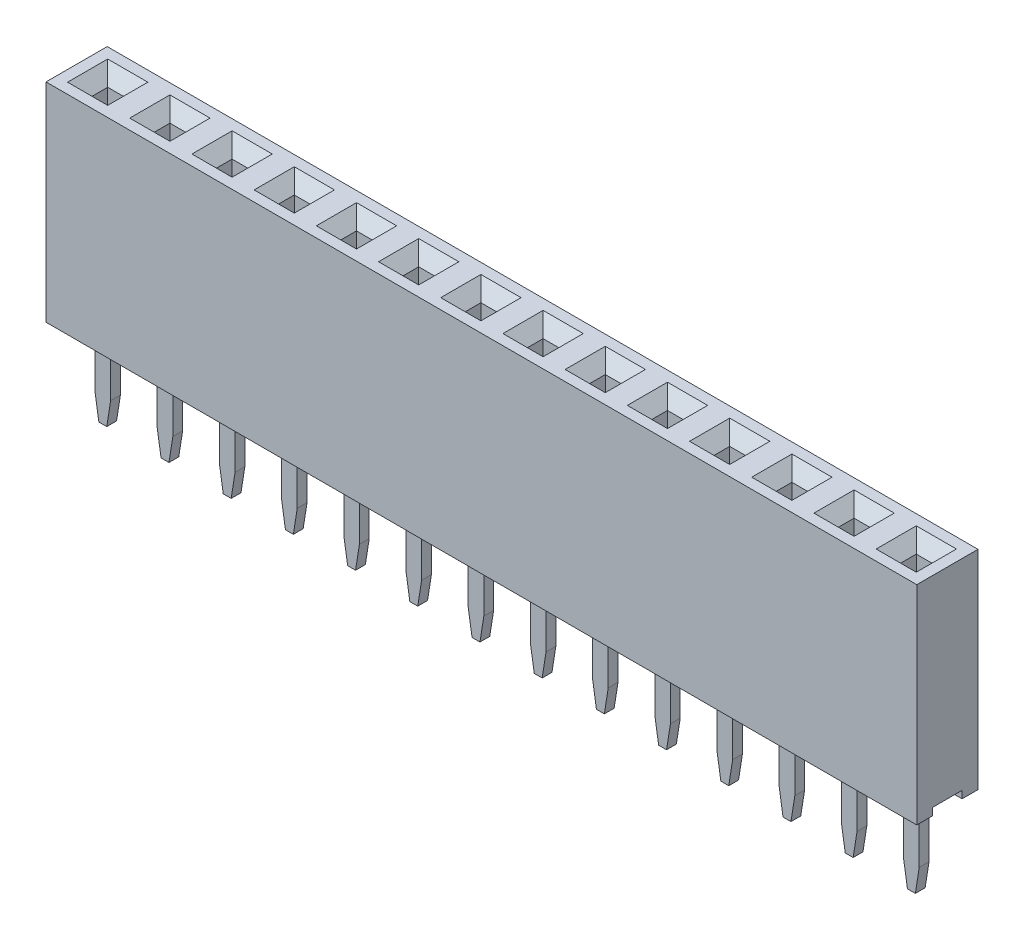
from build123d import *
from OCP.BRepFilletAPI import BRepFilletAPI_MakeChamfer

# Parameters (mm, degrees)
SKETCH1_W                   = 2.54
SKETCH1_H                   = 2.5
BOSS_EXTRUDE1_DEPTH         = 8.5
SKETCH2_W                   = 2.54
SKETCH2_H                   = 1.2
CUT_EXTRUDE1_DEPTH          = 0.3
CUT_EXTRUDE2_START          = -6
SKETCH3_W                   = 0.64
SKETCH3_H                   = 0.64
CUT_EXTRUDE2_DEPTH          = 15.68477979
CHAMFER1_SIZE               = 0.5
SKETCH4_W                   = 0.64
SKETCH4_H                   = 0.4
BOSS_EXTRUDE2_DEPTH         = 3.8
CHAMFER2_SIZE               = 1
CHAMFER2_SIZE2              = 0.15838444
LPATTERN1_COUNT             = 14
LPATTERN1_PITCH             = 2.54
CHAMFER1_OF_LPATTERN1_SIZE  = 0.5
CHAMFER2_OF_LPATTERN1_SIZE  = 1
CHAMFER2_OF_LPATTERN1_SIZE2 = 0.15838444


with BuildPart() as part:
    # Sketch1 → Boss-Extrude1 (new body)
    with BuildSketch(Plane(origin=(0, 0, 0), x_dir=(1, 0, 0), z_dir=(0, 1, 0))):
        Rectangle(SKETCH1_W, SKETCH1_H)
    boss_extrude1 = extrude(amount=BOSS_EXTRUDE1_DEPTH)

    # Sketch2 → Cut-Extrude1 (cut)
    with BuildSketch(Plane.XZ):
        Rectangle(SKETCH2_W, SKETCH2_H)
    cut_extrude1 = extrude(amount=-CUT_EXTRUDE1_DEPTH, mode=Mode.SUBTRACT)

    # Sketch3 → Cut-Extrude2 (cut)
    with BuildSketch(Plane(origin=(0, 8.5, 0), x_dir=(1, 0, 0), z_dir=(0, 1, 0)).offset(CUT_EXTRUDE2_START)):
        Rectangle(SKETCH3_W, SKETCH3_H)
    cut_extrude2 = extrude(amount=CUT_EXTRUDE2_DEPTH, mode=Mode.SUBTRACT)

    # Chamfer1
    chamfer1_edges = [part.edges().sort_by_distance(p)[0] for p in [
        (0, 8.5, 0.32),
        (-0.32, 8.5, 0),
        (0, 8.5, -0.32),
        (0.32, 8.5, 0),
    ]]
    chamfer(chamfer1_edges, length=CHAMFER1_SIZE)

    # Sketch4 → Boss-Extrude2 (add)
    with BuildSketch(Plane.XZ.offset(-0.3)):
        Rectangle(SKETCH4_W, SKETCH4_H)
    boss_extrude2 = extrude(amount=BOSS_EXTRUDE2_DEPTH)

    # Chamfer2: one chamfer whose edges measure the first distance from different faces: ONE call of the kernel's chamfer builder (chamfer() names one face for all edges)
    chamfer2_edges_1 = [part.edges().sort_by_distance(p)[0] for p in [
        (0.32, -3.5, 0),
    ]]
    chamfer2_side_1 = [part.faces().sort_by_distance(p)[0] for p in [
        (0.32, -1.6, 0),
    ]]
    chamfer2_edges_2 = [part.edges().sort_by_distance(p)[0] for p in [
        (-0.32, -3.5, 0),
    ]]
    chamfer2_side_2 = [part.faces().sort_by_distance(p)[0] for p in [
        (-0.32, -1.6, 0),
    ]]
    chamfer2 = BRepFilletAPI_MakeChamfer(part.part.solid().wrapped)
    for e in chamfer2_edges_1:
        chamfer2.Add(CHAMFER2_SIZE, CHAMFER2_SIZE2, e.wrapped, chamfer2_side_1[0].wrapped)  # the first distance lies on this face
    for e in chamfer2_edges_2:
        chamfer2.Add(CHAMFER2_SIZE, CHAMFER2_SIZE2, e.wrapped, chamfer2_side_2[0].wrapped)  # the first distance lies on this face
    add(Compound.cast(chamfer2.Shape()), mode=Mode.REPLACE)

    # LPattern1: Boss-Extrude1, Cut-Extrude1, Cut-Extrude2, Boss-Extrude2 ×14
    with Locations(*[(-i * LPATTERN1_PITCH, 0, 0) for i in range(1, LPATTERN1_COUNT)]):
        add(boss_extrude1)
        add(cut_extrude1, mode=Mode.SUBTRACT)
        add(cut_extrude2, mode=Mode.SUBTRACT)
        add(boss_extrude2)

    # Chamfer1 of LPattern1
    chamfer1_of_lpattern1_edges = [part.edges().sort_by_distance(p)[0] for p in [
        (-2.54, 8.5, 0.32),
        (-2.86, 8.5, 0),
        (-2.54, 8.5, -0.32),
        (-2.22, 8.5, 0),
        (-5.08, 8.5, 0.32),
        (-5.4, 8.5, 0),
        (-5.08, 8.5, -0.32),
        (-4.76, 8.5, 0),
        (-7.62, 8.5, 0.32),
        (-7.94, 8.5, 0),
        (-7.62, 8.5, -0.32),
        (-7.3, 8.5, 0),
        (-10.16, 8.5, 0.32),
        (-10.48, 8.5, 0),
        (-10.16, 8.5, -0.32),
        (-9.84, 8.5, 0),
        (-12.7, 8.5, 0.32),
        (-13.02, 8.5, 0),
        (-12.7, 8.5, -0.32),
        (-12.38, 8.5, 0),
        (-15.24, 8.5, 0.32),
        (-15.56, 8.5, 0),
        (-15.24, 8.5, -0.32),
        (-14.92, 8.5, 0),
        (-17.78, 8.5, 0.32),
        (-18.1, 8.5, 0),
        (-17.78, 8.5, -0.32),
        (-17.46, 8.5, 0),
        (-20.32, 8.5, 0.32),
        (-20.64, 8.5, 0),
        (-20.32, 8.5, -0.32),
        (-20, 8.5, 0),
        (-22.86, 8.5, 0.32),
        (-23.18, 8.5, 0),
        (-22.86, 8.5, -0.32),
        (-22.54, 8.5, 0),
        (-25.4, 8.5, 0.32),
        (-25.72, 8.5, 0),
        (-25.4, 8.5, -0.32),
        (-25.08, 8.5, 0),
        (-27.94, 8.5, 0.32),
        (-28.26, 8.5, 0),
        (-27.94, 8.5, -0.32),
        (-27.62, 8.5, 0),
        (-30.48, 8.5, 0.32),
        (-30.8, 8.5, 0),
        (-30.48, 8.5, -0.32),
        (-30.16, 8.5, 0),
        (-33.02, 8.5, 0.32),
        (-33.34, 8.5, 0),
        (-33.02, 8.5, -0.32),
        (-32.7, 8.5, 0),
    ]]
    chamfer(chamfer1_of_lpattern1_edges, length=CHAMFER1_OF_LPATTERN1_SIZE)

    # Chamfer2 of LPattern1: one chamfer whose edges measure the first distance from different faces: ONE call of the kernel's chamfer builder (chamfer() names one face for all edges)
    chamfer2_of_lpattern1_edges_1 = [part.edges().sort_by_distance(p)[0] for p in [
        (-2.22, -3.5, 0),
    ]]
    chamfer2_of_lpattern1_side_1 = [part.faces().sort_by_distance(p)[0] for p in [
        (-2.22, -1.6, 0),
    ]]
    chamfer2_of_lpattern1_edges_2 = [part.edges().sort_by_distance(p)[0] for p in [
        (-2.86, -3.5, 0),
    ]]
    chamfer2_of_lpattern1_side_2 = [part.faces().sort_by_distance(p)[0] for p in [
        (-2.86, -1.6, 0),
    ]]
    chamfer2_of_lpattern1_edges_3 = [part.edges().sort_by_distance(p)[0] for p in [
        (-4.76, -3.5, 0),
    ]]
    chamfer2_of_lpattern1_side_3 = [part.faces().sort_by_distance(p)[0] for p in [
        (-4.76, -1.6, 0),
    ]]
    chamfer2_of_lpattern1_edges_4 = [part.edges().sort_by_distance(p)[0] for p in [
        (-5.4, -3.5, 0),
    ]]
    chamfer2_of_lpattern1_side_4 = [part.faces().sort_by_distance(p)[0] for p in [
        (-5.4, -1.6, 0),
    ]]
    chamfer2_of_lpattern1_edges_5 = [part.edges().sort_by_distance(p)[0] for p in [
        (-7.3, -3.5, 0),
    ]]
    chamfer2_of_lpattern1_side_5 = [part.faces().sort_by_distance(p)[0] for p in [
        (-7.3, -1.6, 0),
    ]]
    chamfer2_of_lpattern1_edges_6 = [part.edges().sort_by_distance(p)[0] for p in [
        (-7.94, -3.5, 0),
    ]]
    chamfer2_of_lpattern1_side_6 = [part.faces().sort_by_distance(p)[0] for p in [
        (-7.94, -1.6, 0),
    ]]
    chamfer2_of_lpattern1_edges_7 = [part.edges().sort_by_distance(p)[0] for p in [
        (-9.84, -3.5, 0),
    ]]
    chamfer2_of_lpattern1_side_7 = [part.faces().sort_by_distance(p)[0] for p in [
        (-9.84, -1.6, 0),
    ]]
    chamfer2_of_lpattern1_edges_8 = [part.edges().sort_by_distance(p)[0] for p in [
        (-10.48, -3.5, 0),
    ]]
    chamfer2_of_lpattern1_side_8 = [part.faces().sort_by_distance(p)[0] for p in [
        (-10.48, -1.6, 0),
    ]]
    chamfer2_of_lpattern1_edges_9 = [part.edges().sort_by_distance(p)[0] for p in [
        (-12.38, -3.5, 0),
    ]]
    chamfer2_of_lpattern1_side_9 = [part.faces().sort_by_distance(p)[0] for p in [
        (-12.38, -1.6, 0),
    ]]
    chamfer2_of_lpattern1_edges_10 = [part.edges().sort_by_distance(p)[0] for p in [
        (-13.02, -3.5, 0),
    ]]
    chamfer2_of_lpattern1_side_10 = [part.faces().sort_by_distance(p)[0] for p in [
        (-13.02, -1.6, 0),
    ]]
    chamfer2_of_lpattern1_edges_11 = [part.edges().sort_by_distance(p)[0] for p in [
        (-14.92, -3.5, 0),
    ]]
    chamfer2_of_lpattern1_side_11 = [part.faces().sort_by_distance(p)[0] for p in [
        (-14.92, -1.6, 0),
    ]]
    chamfer2_of_lpattern1_edges_12 = [part.edges().sort_by_distance(p)[0] for p in [
        (-15.56, -3.5, 0),
    ]]
    chamfer2_of_lpattern1_side_12 = [part.faces().sort_by_distance(p)[0] for p in [
        (-15.56, -1.6, 0),
    ]]
    chamfer2_of_lpattern1_edges_13 = [part.edges().sort_by_distance(p)[0] for p in [
        (-17.46, -3.5, 0),
    ]]
    chamfer2_of_lpattern1_side_13 = [part.faces().sort_by_distance(p)[0] for p in [
        (-17.46, -1.6, 0),
    ]]
    chamfer2_of_lpattern1_edges_14 = [part.edges().sort_by_distance(p)[0] for p in [
        (-18.1, -3.5, 0),
    ]]
    chamfer2_of_lpattern1_side_14 = [part.faces().sort_by_distance(p)[0] for p in [
        (-18.1, -1.6, 0),
    ]]
    chamfer2_of_lpattern1_edges_15 = [part.edges().sort_by_distance(p)[0] for p in [
        (-20, -3.5, 0),
    ]]
    chamfer2_of_lpattern1_side_15 = [part.faces().sort_by_distance(p)[0] for p in [
        (-20, -1.6, 0),
    ]]
    chamfer2_of_lpattern1_edges_16 = [part.edges().sort_by_distance(p)[0] for p in [
        (-20.64, -3.5, 0),
    ]]
    chamfer2_of_lpattern1_side_16 = [part.faces().sort_by_distance(p)[0] for p in [
        (-20.64, -1.6, 0),
    ]]
    chamfer2_of_lpattern1_edges_17 = [part.edges().sort_by_distance(p)[0] for p in [
        (-22.54, -3.5, 0),
    ]]
    chamfer2_of_lpattern1_side_17 = [part.faces().sort_by_distance(p)[0] for p in [
        (-22.54, -1.6, 0),
    ]]
    chamfer2_of_lpattern1_edges_18 = [part.edges().sort_by_distance(p)[0] for p in [
        (-23.18, -3.5, 0),
    ]]
    chamfer2_of_lpattern1_side_18 = [part.faces().sort_by_distance(p)[0] for p in [
        (-23.18, -1.6, 0),
    ]]
    chamfer2_of_lpattern1_edges_19 = [part.edges().sort_by_distance(p)[0] for p in [
        (-25.08, -3.5, 0),
    ]]
    chamfer2_of_lpattern1_side_19 = [part.faces().sort_by_distance(p)[0] for p in [
        (-25.08, -1.6, 0),
    ]]
    chamfer2_of_lpattern1_edges_20 = [part.edges().sort_by_distance(p)[0] for p in [
        (-25.72, -3.5, 0),
    ]]
    chamfer2_of_lpattern1_side_20 = [part.faces().sort_by_distance(p)[0] for p in [
        (-25.72, -1.6, 0),
    ]]
    chamfer2_of_lpattern1_edges_21 = [part.edges().sort_by_distance(p)[0] for p in [
        (-27.62, -3.5, 0),
    ]]
    chamfer2_of_lpattern1_side_21 = [part.faces().sort_by_distance(p)[0] for p in [
        (-27.62, -1.6, 0),
    ]]
    chamfer2_of_lpattern1_edges_22 = [part.edges().sort_by_distance(p)[0] for p in [
        (-28.26, -3.5, 0),
    ]]
    chamfer2_of_lpattern1_side_22 = [part.faces().sort_by_distance(p)[0] for p in [
        (-28.26, -1.6, 0),
    ]]
    chamfer2_of_lpattern1_edges_23 = [part.edges().sort_by_distance(p)[0] for p in [
        (-30.16, -3.5, 0),
    ]]
    chamfer2_of_lpattern1_side_23 = [part.faces().sort_by_distance(p)[0] for p in [
        (-30.16, -1.6, 0),
    ]]
    chamfer2_of_lpattern1_edges_24 = [part.edges().sort_by_distance(p)[0] for p in [
        (-30.8, -3.5, 0),
    ]]
    chamfer2_of_lpattern1_side_24 = [part.faces().sort_by_distance(p)[0] for p in [
        (-30.8, -1.6, 0),
    ]]
    chamfer2_of_lpattern1_edges_25 = [part.edges().sort_by_distance(p)[0] for p in [
        (-32.7, -3.5, 0),
    ]]
    chamfer2_of_lpattern1_side_25 = [part.faces().sort_by_distance(p)[0] for p in [
        (-32.7, -1.6, 0),
    ]]
    chamfer2_of_lpattern1_edges_26 = [part.edges().sort_by_distance(p)[0] for p in [
        (-33.34, -3.5, 0),
    ]]
    chamfer2_of_lpattern1_side_26 = [part.faces().sort_by_distance(p)[0] for p in [
        (-33.34, -1.6, 0),
    ]]
    chamfer2_of_lpattern1 = BRepFilletAPI_MakeChamfer(part.part.solid().wrapped)
    for e in chamfer2_of_lpattern1_edges_1:
        chamfer2_of_lpattern1.Add(CHAMFER2_OF_LPATTERN1_SIZE, CHAMFER2_OF_LPATTERN1_SIZE2, e.wrapped, chamfer2_of_lpattern1_side_1[0].wrapped)  # the first distance lies on this face
    for e in chamfer2_of_lpattern1_edges_2:
        chamfer2_of_lpattern1.Add(CHAMFER2_OF_LPATTERN1_SIZE, CHAMFER2_OF_LPATTERN1_SIZE2, e.wrapped, chamfer2_of_lpattern1_side_2[0].wrapped)  # the first distance lies on this face
    for e in chamfer2_of_lpattern1_edges_3:
        chamfer2_of_lpattern1.Add(CHAMFER2_OF_LPATTERN1_SIZE, CHAMFER2_OF_LPATTERN1_SIZE2, e.wrapped, chamfer2_of_lpattern1_side_3[0].wrapped)  # the first distance lies on this face
    for e in chamfer2_of_lpattern1_edges_4:
        chamfer2_of_lpattern1.Add(CHAMFER2_OF_LPATTERN1_SIZE, CHAMFER2_OF_LPATTERN1_SIZE2, e.wrapped, chamfer2_of_lpattern1_side_4[0].wrapped)  # the first distance lies on this face
    for e in chamfer2_of_lpattern1_edges_5:
        chamfer2_of_lpattern1.Add(CHAMFER2_OF_LPATTERN1_SIZE, CHAMFER2_OF_LPATTERN1_SIZE2, e.wrapped, chamfer2_of_lpattern1_side_5[0].wrapped)  # the first distance lies on this face
    for e in chamfer2_of_lpattern1_edges_6:
        chamfer2_of_lpattern1.Add(CHAMFER2_OF_LPATTERN1_SIZE, CHAMFER2_OF_LPATTERN1_SIZE2, e.wrapped, chamfer2_of_lpattern1_side_6[0].wrapped)  # the first distance lies on this face
    for e in chamfer2_of_lpattern1_edges_7:
        chamfer2_of_lpattern1.Add(CHAMFER2_OF_LPATTERN1_SIZE, CHAMFER2_OF_LPATTERN1_SIZE2, e.wrapped, chamfer2_of_lpattern1_side_7[0].wrapped)  # the first distance lies on this face
    for e in chamfer2_of_lpattern1_edges_8:
        chamfer2_of_lpattern1.Add(CHAMFER2_OF_LPATTERN1_SIZE, CHAMFER2_OF_LPATTERN1_SIZE2, e.wrapped, chamfer2_of_lpattern1_side_8[0].wrapped)  # the first distance lies on this face
    for e in chamfer2_of_lpattern1_edges_9:
        chamfer2_of_lpattern1.Add(CHAMFER2_OF_LPATTERN1_SIZE, CHAMFER2_OF_LPATTERN1_SIZE2, e.wrapped, chamfer2_of_lpattern1_side_9[0].wrapped)  # the first distance lies on this face
    for e in chamfer2_of_lpattern1_edges_10:
        chamfer2_of_lpattern1.Add(CHAMFER2_OF_LPATTERN1_SIZE, CHAMFER2_OF_LPATTERN1_SIZE2, e.wrapped, chamfer2_of_lpattern1_side_10[0].wrapped)  # the first distance lies on this face
    for e in chamfer2_of_lpattern1_edges_11:
        chamfer2_of_lpattern1.Add(CHAMFER2_OF_LPATTERN1_SIZE, CHAMFER2_OF_LPATTERN1_SIZE2, e.wrapped, chamfer2_of_lpattern1_side_11[0].wrapped)  # the first distance lies on this face
    for e in chamfer2_of_lpattern1_edges_12:
        chamfer2_of_lpattern1.Add(CHAMFER2_OF_LPATTERN1_SIZE, CHAMFER2_OF_LPATTERN1_SIZE2, e.wrapped, chamfer2_of_lpattern1_side_12[0].wrapped)  # the first distance lies on this face
    for e in chamfer2_of_lpattern1_edges_13:
        chamfer2_of_lpattern1.Add(CHAMFER2_OF_LPATTERN1_SIZE, CHAMFER2_OF_LPATTERN1_SIZE2, e.wrapped, chamfer2_of_lpattern1_side_13[0].wrapped)  # the first distance lies on this face
    for e in chamfer2_of_lpattern1_edges_14:
        chamfer2_of_lpattern1.Add(CHAMFER2_OF_LPATTERN1_SIZE, CHAMFER2_OF_LPATTERN1_SIZE2, e.wrapped, chamfer2_of_lpattern1_side_14[0].wrapped)  # the first distance lies on this face
    for e in chamfer2_of_lpattern1_edges_15:
        chamfer2_of_lpattern1.Add(CHAMFER2_OF_LPATTERN1_SIZE, CHAMFER2_OF_LPATTERN1_SIZE2, e.wrapped, chamfer2_of_lpattern1_side_15[0].wrapped)  # the first distance lies on this face
    for e in chamfer2_of_lpattern1_edges_16:
        chamfer2_of_lpattern1.Add(CHAMFER2_OF_LPATTERN1_SIZE, CHAMFER2_OF_LPATTERN1_SIZE2, e.wrapped, chamfer2_of_lpattern1_side_16[0].wrapped)  # the first distance lies on this face
    for e in chamfer2_of_lpattern1_edges_17:
        chamfer2_of_lpattern1.Add(CHAMFER2_OF_LPATTERN1_SIZE, CHAMFER2_OF_LPATTERN1_SIZE2, e.wrapped, chamfer2_of_lpattern1_side_17[0].wrapped)  # the first distance lies on this face
    for e in chamfer2_of_lpattern1_edges_18:
        chamfer2_of_lpattern1.Add(CHAMFER2_OF_LPATTERN1_SIZE, CHAMFER2_OF_LPATTERN1_SIZE2, e.wrapped, chamfer2_of_lpattern1_side_18[0].wrapped)  # the first distance lies on this face
    for e in chamfer2_of_lpattern1_edges_19:
        chamfer2_of_lpattern1.Add(CHAMFER2_OF_LPATTERN1_SIZE, CHAMFER2_OF_LPATTERN1_SIZE2, e.wrapped, chamfer2_of_lpattern1_side_19[0].wrapped)  # the first distance lies on this face
    for e in chamfer2_of_lpattern1_edges_20:
        chamfer2_of_lpattern1.Add(CHAMFER2_OF_LPATTERN1_SIZE, CHAMFER2_OF_LPATTERN1_SIZE2, e.wrapped, chamfer2_of_lpattern1_side_20[0].wrapped)  # the first distance lies on this face
    for e in chamfer2_of_lpattern1_edges_21:
        chamfer2_of_lpattern1.Add(CHAMFER2_OF_LPATTERN1_SIZE, CHAMFER2_OF_LPATTERN1_SIZE2, e.wrapped, chamfer2_of_lpattern1_side_21[0].wrapped)  # the first distance lies on this face
    for e in chamfer2_of_lpattern1_edges_22:
        chamfer2_of_lpattern1.Add(CHAMFER2_OF_LPATTERN1_SIZE, CHAMFER2_OF_LPATTERN1_SIZE2, e.wrapped, chamfer2_of_lpattern1_side_22[0].wrapped)  # the first distance lies on this face
    for e in chamfer2_of_lpattern1_edges_23:
        chamfer2_of_lpattern1.Add(CHAMFER2_OF_LPATTERN1_SIZE, CHAMFER2_OF_LPATTERN1_SIZE2, e.wrapped, chamfer2_of_lpattern1_side_23[0].wrapped)  # the first distance lies on this face
    for e in chamfer2_of_lpattern1_edges_24:
        chamfer2_of_lpattern1.Add(CHAMFER2_OF_LPATTERN1_SIZE, CHAMFER2_OF_LPATTERN1_SIZE2, e.wrapped, chamfer2_of_lpattern1_side_24[0].wrapped)  # the first distance lies on this face
    for e in chamfer2_of_lpattern1_edges_25:
        chamfer2_of_lpattern1.Add(CHAMFER2_OF_LPATTERN1_SIZE, CHAMFER2_OF_LPATTERN1_SIZE2, e.wrapped, chamfer2_of_lpattern1_side_25[0].wrapped)  # the first distance lies on this face
    for e in chamfer2_of_lpattern1_edges_26:
        chamfer2_of_lpattern1.Add(CHAMFER2_OF_LPATTERN1_SIZE, CHAMFER2_OF_LPATTERN1_SIZE2, e.wrapped, chamfer2_of_lpattern1_side_26[0].wrapped)  # the first distance lies on this face
    add(Compound.cast(chamfer2_of_lpattern1.Shape()), mode=Mode.REPLACE)


solid = part.part
